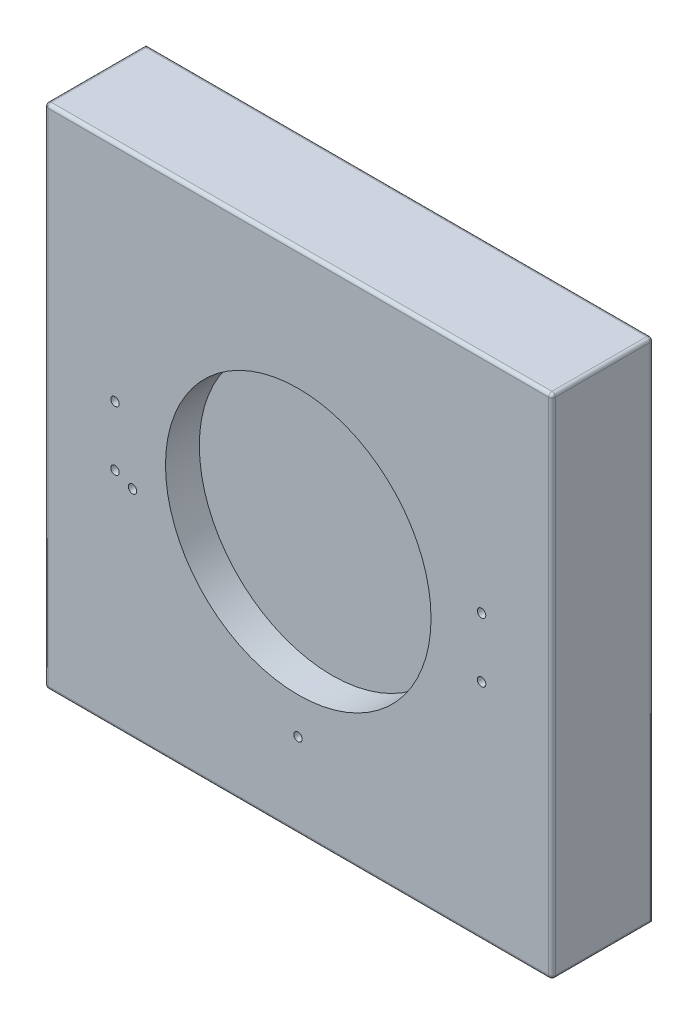
from build123d import *

# Parameters (mm, degrees)
SKETCH1_W                   = 150
SKETCH1_H                   = 150
BOSS_EXTRUDE1_DEPTH         = 30
FILLET1_R                   = 1
SKETCH2_R                   = 39.25
CUT_EXTRUDE4_DEPTH          = 10
TAP_DRILL_FOR_M3X0_5_TAP2_D = 2.5
TAP_DRILL_FOR_M3X0_5_TAP3_D = 2.5
TAP_DRILL_FOR_M3X0_5_TAP5_D = 2.5


with BuildPart() as part:
    # Sketch1 → Boss-Extrude1 (new body)
    with BuildSketch(Plane.XY):
        Rectangle(SKETCH1_W, SKETCH1_H)
    extrude(amount=-BOSS_EXTRUDE1_DEPTH)

    # Fillet1
    fillet1_edges = [part.edges().sort_by_distance(p)[0] for p in [
        (75, -75, -15),
        (-75, -75, -15),
        (-75, 75, -15),
        (75, 0, -30),
        (0, 75, -30),
        (75, 75, -15),
        (0, -75, 0),
        (-75, 0, 0),
        (75, 0, 0),
        (0, 75, 0),
    ]]
    fillet(fillet1_edges, radius=FILLET1_R)

    # Sketch2 → Cut-Extrude4 (cut)
    with BuildSketch(Plane.XY):
        Circle(SKETCH2_R)
    extrude(amount=-CUT_EXTRUDE4_DEPTH, mode=Mode.SUBTRACT)

    # Tap Drill for M3x0.5 Tap2 (through all)
    with Locations(Plane.XY):
        with Locations((-54.190883488, -8.8), (-54.190883488, 8.8), (54.190883488, -8.8), (54.190883488, 8.8)):
            Hole(TAP_DRILL_FOR_M3X0_5_TAP2_D / 2)

    # Tap Drill for M3x0.5 Tap3 (through all)
    with Locations(Plane.XY):
        with Locations((-49, -11)):
            Hole(TAP_DRILL_FOR_M3X0_5_TAP3_D / 2)

    # Tap Drill for M3x0.5 Tap5 (through all)
    with Locations(Plane.XY):
        with Locations((-0.083892693, -49.999977478)):
            Hole(TAP_DRILL_FOR_M3X0_5_TAP5_D / 2)


solid = part.part
